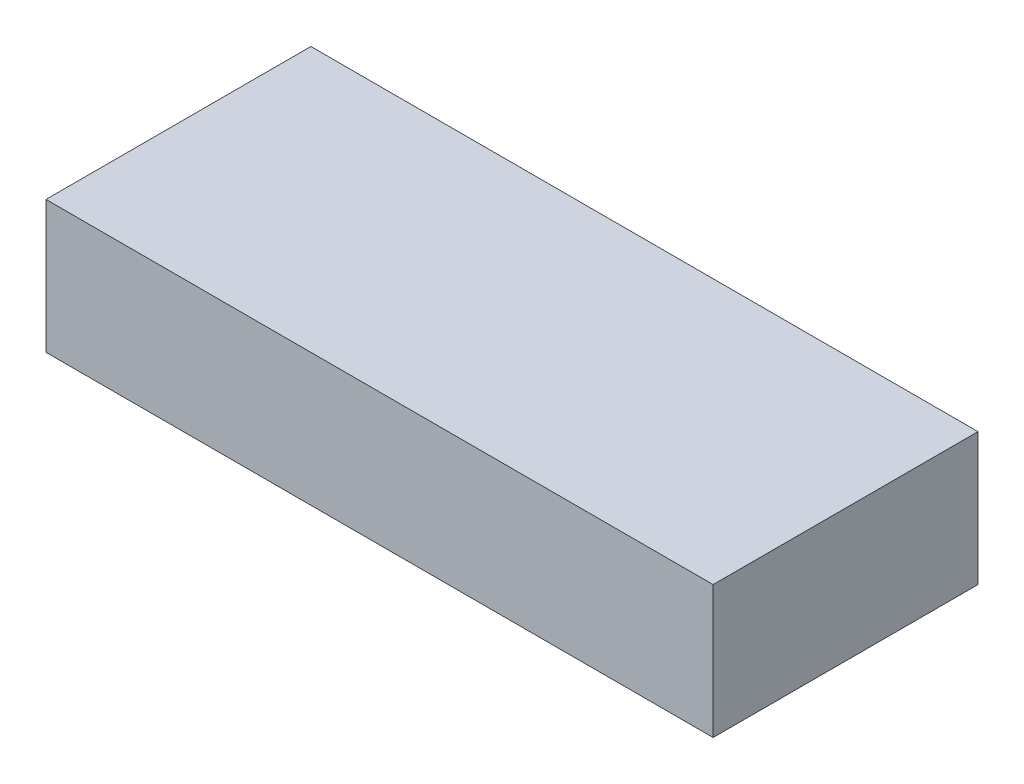
from build123d import *

# Parameters (mm, degrees)
SKETCH1_W           = 431.8
SKETCH1_H           = 171.45
BOSS_EXTRUDE1_DEPTH = 85.725
CUT_EXTRUDE1_DEPTH  = 73.025
CHAMFER1_SIZE       = 0.635


with BuildPart() as part:
    # Sketch1 → Boss-Extrude1 (new body)
    with BuildSketch(Plane(origin=(0, 0, 0), x_dir=(1, 0, 0), z_dir=(0, 1, 0))):
        Rectangle(SKETCH1_W, SKETCH1_H)
    extrude(amount=BOSS_EXTRUDE1_DEPTH)

    # Sketch2 → Cut-Extrude1 (cut)
    with BuildSketch(Plane.XZ):
        with BuildLine():
            Line((178.806416914, 72.140394915), (-178.806416914, 72.140394915))
            ThreePointArc((-178.806416914, 72.140394915), (-195.429774677, 65.254774677), (-202.315394915, 48.631416914))
            Line((-202.315394915, 48.631416914), (-202.315394915, -48.631416914))
            ThreePointArc((-202.315394915, -48.631416914), (-195.429774677, -65.254774677), (-178.806416914, -72.140394915))
            Line((-178.806416914, -72.140394915), (178.806416914, -72.140394915))
            ThreePointArc((178.806416914, -72.140394915), (195.429774677, -65.254774677), (202.315394915, -48.631416914))
            Line((202.315394915, -48.631416914), (202.315394915, 48.631416914))
            ThreePointArc((202.315394915, 48.631416914), (195.429774677, 65.254774677), (178.806416914, 72.140394915))
        make_face()
    extrude(amount=-CUT_EXTRUDE1_DEPTH, mode=Mode.SUBTRACT)

    # Chamfer1
    chamfer1_edges = [part.edges().sort_by_distance(p)[0] for p in [
        (195.429774677, 0, 65.254774677),
        (195.429774677, 0, -65.254774677),
        (-195.429774677, 0, -65.254774677),
        (0, 0, 72.140394915),
        (-195.429774677, 0, 65.254774677),
        (-202.315394915, 0, 0),
        (0, 0, -72.140394915),
        (202.315394915, 0, 0),
    ]]
    chamfer(chamfer1_edges, length=CHAMFER1_SIZE)


solid = part.part
